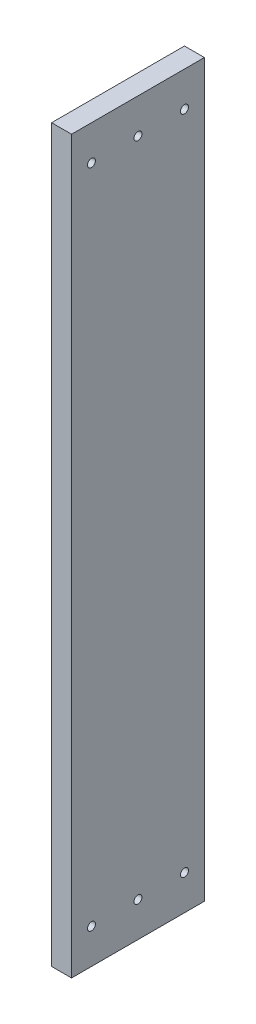
from build123d import *

# Parameters (mm, degrees)
SKETCH1_W           = 19.05
SKETCH1_H           = 127
BOSS_EXTRUDE1_DEPTH = 698.5
SKETCH2_R           = 3.81
CUT_EXTRUDE1_DEPTH  = 67.818


with BuildPart() as part:
    # Sketch1 → Boss-Extrude1 (new body)
    with BuildSketch(Plane(origin=(0, 0, 0), x_dir=(1, 0, 0), z_dir=(0, 1, 0))):
        with Locations((9.525, 63.5)):
            Rectangle(SKETCH1_W, SKETCH1_H)
    extrude(amount=BOSS_EXTRUDE1_DEPTH)

    # Sketch2 → Cut-Extrude1 (cut)
    with BuildSketch(Plane(origin=(19.05, 0, 0), x_dir=(0, 0, -1), z_dir=(1, 0, 0))):
        with Locations((107.95, 665.226)):
            Circle(SKETCH2_R)
        with Locations((63.5, 665.226)):
            Circle(SKETCH2_R)
        with Locations((19.05, 665.226)):
            Circle(SKETCH2_R)
        with Locations((19.05, 33.274)):
            Circle(SKETCH2_R)
        with Locations((63.5, 33.274)):
            Circle(SKETCH2_R)
        with Locations((107.95, 33.274)):
            Circle(SKETCH2_R)
    extrude(amount=-CUT_EXTRUDE1_DEPTH, mode=Mode.SUBTRACT)


solid = part.part
